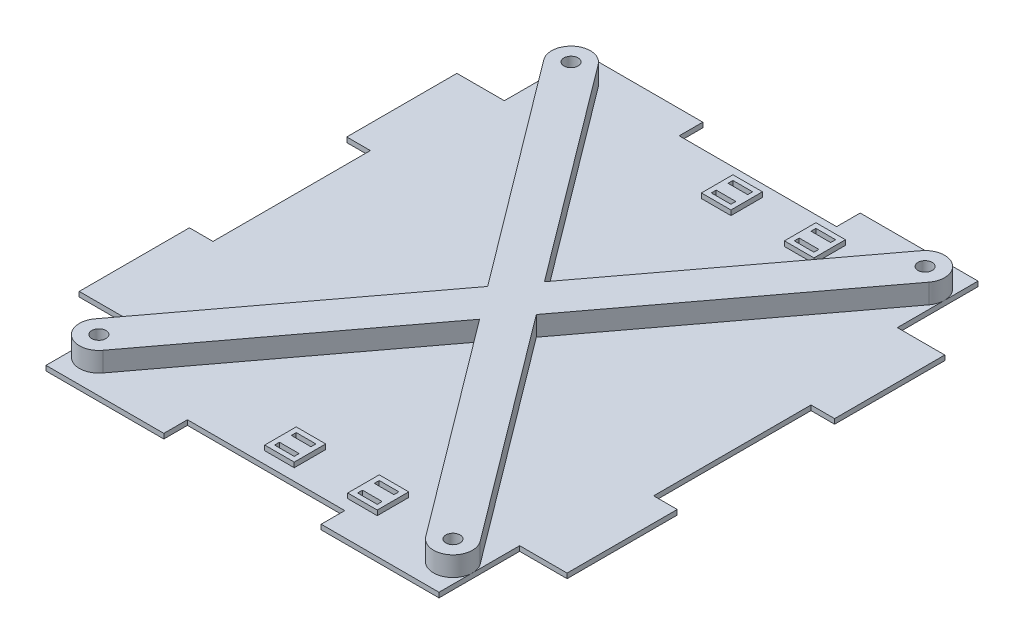
from build123d import *

# Parameters (mm, degrees)
SKETCH1_R           = 2.286
MAIN_BODY_DEPTH     = 1.5875
SKETCH3_R           = 2.286
BOSS_EXTRUDE1_DEPTH = 6.35
CUT_EXTRUDE2_REACH  = 3.587
SKETCH2_W           = 6.35
SKETCH2_H           = 1.5875
SKETCH5_W           = 6.35
SKETCH5_H           = 1.5875
BOSS_EXTRUDE3_DEPTH = 1.5875


with BuildPart() as part:
    # Sketch1 → Main Body (new body)
    with BuildSketch(Plane(origin=(0, 0, 0), x_dir=(1, 0, 0), z_dir=(0, 1, 0))):
        Polygon((-25.4, 86.995), (-63.43142, 86.995), (-63.43142, 60.96), (-78.74, 60.96), (-78.74, 25.4), (-71.12, 25.4), (-71.12, -25.4), (-78.74, -25.4), (-78.74, -60.96), (-63.43142, -60.96), (-63.43142, -86.995), (-25.4, -86.995), (-25.4, -79.375), (25.4, -79.375), (25.4, -86.995), (63.43142, -86.995), (63.43142, -60.96), (78.74, -60.96), (78.74, -25.4), (71.12, -25.4), (71.12, 25.4), (78.74, 25.4), (78.74, 60.96), (63.43142, 60.96), (63.43142, 86.995), (25.4, 86.995), (25.4, 79.375), (-25.4, 79.375), align=None)
        with Locations((-57.15, 76.2)):
            Circle(SKETCH1_R, mode=Mode.SUBTRACT)
        with Locations((57.15, 76.2)):
            Circle(SKETCH1_R, mode=Mode.SUBTRACT)
        with Locations((57.15, -76.2)):
            Circle(SKETCH1_R, mode=Mode.SUBTRACT)
        with Locations((-57.15, -76.2)):
            Circle(SKETCH1_R, mode=Mode.SUBTRACT)
    extrude(amount=MAIN_BODY_DEPTH)

    # Sketch3 → Boss-Extrude1 (add)
    with BuildSketch(Plane(origin=(0, 1.5875, 0), x_dir=(1, 0, 0), z_dir=(0, 1, 0))):
        with BuildLine():
            Line((62.175136, -72.431148), (7.851775, 0))
            Line((7.851775, 0), (62.175136, 72.431148))
            ThreePointArc((62.175136, 72.431148), (60.918852, 81.225136), (52.124864, 79.968852))
            Line((52.124864, 79.968852), (0, 10.469033333))
            Line((0, 10.469033333), (-52.124864, 79.968852))
            ThreePointArc((-52.124864, 79.968852), (-60.918852, 81.225136), (-62.175136, 72.431148))
            Line((-62.175136, 72.431148), (-7.851775, 0))
            Line((-7.851775, 0), (-62.175136, -72.431148))
            ThreePointArc((-62.175136, -72.431148), (-60.918852, -81.225136), (-52.124864, -79.968852))
            Line((-52.124864, -79.968852), (0, -10.469033333))
            Line((0, -10.469033333), (52.124864, -79.968852))
            ThreePointArc((52.124864, -79.968852), (60.918852, -81.225136), (62.175136, -72.431148))
        make_face()
        with Locations((57.15, 76.2)):
            Circle(SKETCH3_R, mode=Mode.SUBTRACT)
        with Locations((57.15, -76.2)):
            Circle(SKETCH3_R, mode=Mode.SUBTRACT)
        with Locations((-57.15, -76.2)):
            Circle(SKETCH3_R, mode=Mode.SUBTRACT)
        with Locations((-57.15, 76.2)):
            Circle(SKETCH3_R, mode=Mode.SUBTRACT)
    extrude(amount=BOSS_EXTRUDE1_DEPTH)

    # Sketch2 → Cut-Extrude2 (cut, up to next)
    with BuildSketch(Plane(origin=(0, 1.5875, 0), x_dir=(1, 0, 0), z_dir=(0, 1, 0)), mode=Mode.PRIVATE) as cut_extrude2_sk1:
        with Locations((0.508, -67.78625)):
            Rectangle(SKETCH2_W, SKETCH2_H)
    cut_extrude2_tool1 = extrude(cut_extrude2_sk1.sketch, amount=-CUT_EXTRUDE2_REACH, mode=Mode.PRIVATE) & part.part
    add(cut_extrude2_tool1.solids().sort_by_distance((0.508, 1.5875, 67.78625))[0], mode=Mode.SUBTRACT)
    # Sketch2 → Cut-Extrude2 (cut, up to next)
    with BuildSketch(Plane(origin=(0, 1.5875, 0), x_dir=(1, 0, 0), z_dir=(0, 1, 0)), mode=Mode.PRIVATE) as cut_extrude2_sk2:
        with Locations((0.508, -73.18375)):
            Rectangle(SKETCH2_W, SKETCH2_H)
    cut_extrude2_tool2 = extrude(cut_extrude2_sk2.sketch, amount=-CUT_EXTRUDE2_REACH, mode=Mode.PRIVATE) & part.part
    add(cut_extrude2_tool2.solids().sort_by_distance((0.508, 1.5875, 73.18375))[0], mode=Mode.SUBTRACT)
    # Sketch2 → Cut-Extrude2 (cut, up to next)
    with BuildSketch(Plane(origin=(0, 1.5875, 0), x_dir=(1, 0, 0), z_dir=(0, 1, 0)), mode=Mode.PRIVATE) as cut_extrude2_sk3:
        with Locations((27.305, -67.78625)):
            Rectangle(SKETCH2_W, SKETCH2_H)
    cut_extrude2_tool3 = extrude(cut_extrude2_sk3.sketch, amount=-CUT_EXTRUDE2_REACH, mode=Mode.PRIVATE) & part.part
    add(cut_extrude2_tool3.solids().sort_by_distance((27.305, 1.5875, 67.78625))[0], mode=Mode.SUBTRACT)
    # Sketch2 → Cut-Extrude2 (cut, up to next)
    with BuildSketch(Plane(origin=(0, 1.5875, 0), x_dir=(1, 0, 0), z_dir=(0, 1, 0)), mode=Mode.PRIVATE) as cut_extrude2_sk4:
        with Locations((27.305, -73.18375)):
            Rectangle(SKETCH2_W, SKETCH2_H)
    cut_extrude2_tool4 = extrude(cut_extrude2_sk4.sketch, amount=-CUT_EXTRUDE2_REACH, mode=Mode.PRIVATE) & part.part
    add(cut_extrude2_tool4.solids().sort_by_distance((27.305, 1.5875, 73.18375))[0], mode=Mode.SUBTRACT)
    # Sketch2 → Cut-Extrude2 (cut, up to next)
    with BuildSketch(Plane(origin=(0, 1.5875, 0), x_dir=(1, 0, 0), z_dir=(0, 1, 0)), mode=Mode.PRIVATE) as cut_extrude2_sk5:
        with Locations((0.508, 67.78625)):
            Rectangle(SKETCH2_W, SKETCH2_H)
    cut_extrude2_tool5 = extrude(cut_extrude2_sk5.sketch, amount=-CUT_EXTRUDE2_REACH, mode=Mode.PRIVATE) & part.part
    add(cut_extrude2_tool5.solids().sort_by_distance((0.508, 1.5875, -67.78625))[0], mode=Mode.SUBTRACT)
    # Sketch2 → Cut-Extrude2 (cut, up to next)
    with BuildSketch(Plane(origin=(0, 1.5875, 0), x_dir=(1, 0, 0), z_dir=(0, 1, 0)), mode=Mode.PRIVATE) as cut_extrude2_sk6:
        with Locations((0.508, 73.18375)):
            Rectangle(SKETCH2_W, SKETCH2_H)
    cut_extrude2_tool6 = extrude(cut_extrude2_sk6.sketch, amount=-CUT_EXTRUDE2_REACH, mode=Mode.PRIVATE) & part.part
    add(cut_extrude2_tool6.solids().sort_by_distance((0.508, 1.5875, -73.18375))[0], mode=Mode.SUBTRACT)
    # Sketch2 → Cut-Extrude2 (cut, up to next)
    with BuildSketch(Plane(origin=(0, 1.5875, 0), x_dir=(1, 0, 0), z_dir=(0, 1, 0)), mode=Mode.PRIVATE) as cut_extrude2_sk7:
        with Locations((27.305, 73.18375)):
            Rectangle(SKETCH2_W, SKETCH2_H)
    cut_extrude2_tool7 = extrude(cut_extrude2_sk7.sketch, amount=-CUT_EXTRUDE2_REACH, mode=Mode.PRIVATE) & part.part
    add(cut_extrude2_tool7.solids().sort_by_distance((27.305, 1.5875, -73.18375))[0], mode=Mode.SUBTRACT)
    # Sketch2 → Cut-Extrude2 (cut, up to next)
    with BuildSketch(Plane(origin=(0, 1.5875, 0), x_dir=(1, 0, 0), z_dir=(0, 1, 0)), mode=Mode.PRIVATE) as cut_extrude2_sk8:
        with Locations((27.305, 67.78625)):
            Rectangle(SKETCH2_W, SKETCH2_H)
    cut_extrude2_tool8 = extrude(cut_extrude2_sk8.sketch, amount=-CUT_EXTRUDE2_REACH, mode=Mode.PRIVATE) & part.part
    add(cut_extrude2_tool8.solids().sort_by_distance((27.305, 1.5875, -67.78625))[0], mode=Mode.SUBTRACT)

    # Sketch5 → Boss-Extrude3 (add)
    with BuildSketch(Plane(origin=(0, 1.5875, 0), x_dir=(1, 0, 0), z_dir=(0, 1, 0))):
        Polygon((-4.2545, -70.8025), (-4.2545, -70.1675), (-4.2545, -65.405), (5.2705, -65.405), (5.2705, -70.1675), (5.2705, -70.8025), (5.2705, -75.565), (-4.2545, -75.565), align=None)
        with Locations((0.508, -67.78625)):
            Rectangle(SKETCH5_W, SKETCH5_H, mode=Mode.SUBTRACT)
        with Locations((0.508, -73.18375)):
            Rectangle(SKETCH5_W, SKETCH5_H, mode=Mode.SUBTRACT)
        Polygon((22.5425, -70.8025), (22.5425, -70.1675), (22.5425, -65.405), (32.0675, -65.405), (32.0675, -70.1675), (32.0675, -70.8025), (32.0675, -75.565), (22.5425, -75.565), align=None)
        with Locations((27.305, -67.78625)):
            Rectangle(SKETCH5_W, SKETCH5_H, mode=Mode.SUBTRACT)
        with Locations((27.305, -73.18375)):
            Rectangle(SKETCH5_W, SKETCH5_H, mode=Mode.SUBTRACT)
        Polygon((-4.2545, 65.405), (5.2705, 65.405), (5.2705, 70.1675), (5.2705, 70.8025), (5.2705, 75.565), (-4.2545, 75.565), (-4.2545, 70.8025), (-4.2545, 70.1675), align=None)
        with Locations((0.508, 73.18375)):
            Rectangle(SKETCH5_W, SKETCH5_H, mode=Mode.SUBTRACT)
        with Locations((0.508, 67.78625)):
            Rectangle(SKETCH5_W, SKETCH5_H, mode=Mode.SUBTRACT)
        Polygon((22.5425, 65.405), (32.0675, 65.405), (32.0675, 70.1675), (32.0675, 70.8025), (32.0675, 75.565), (22.5425, 75.565), (22.5425, 70.8025), (22.5425, 70.1675), align=None)
        with Locations((27.305, 73.18375)):
            Rectangle(SKETCH5_W, SKETCH5_H, mode=Mode.SUBTRACT)
        with Locations((27.305, 67.78625)):
            Rectangle(SKETCH5_W, SKETCH5_H, mode=Mode.SUBTRACT)
    extrude(amount=BOSS_EXTRUDE3_DEPTH)


solid = part.part
